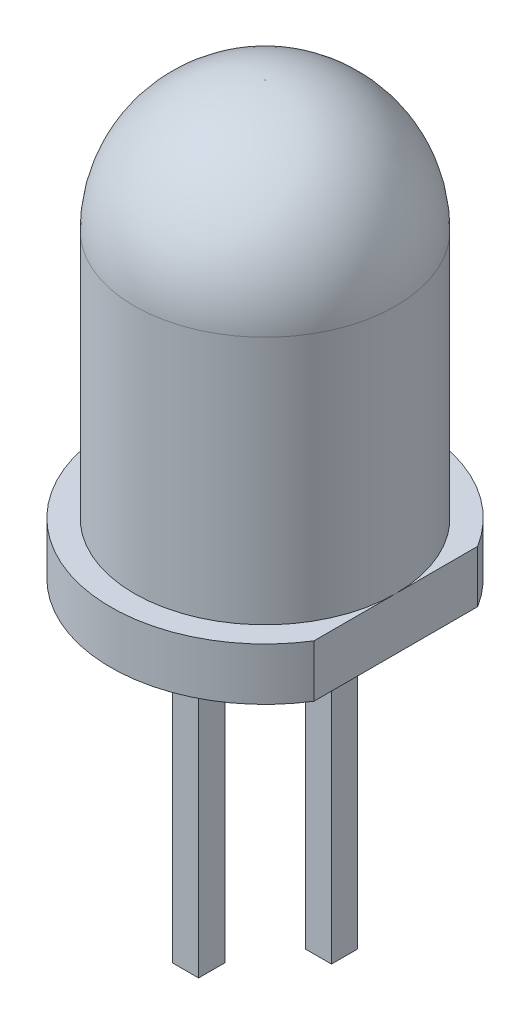
from build123d import *

# Parameters (mm, degrees)
CROQUIS1_R           = 2.95
BASE_DEPTH           = 1
CROQUIS2_R           = 2.5
CUERPO_DEL_LED_DEPTH = 7.25
CROQUIS3_W           = 0.5
CROQUIS3_H           = 0.5
PINES_DEPTH          = 7
CROQUIS4_W           = 0.5
CROQUIS4_H           = 0.5
CORTE_A_CATODO_DEPTH = 1.5
REDONDEO_A_ANODO_R   = 0.5
REDONDEO_A_CATODO_R  = 0.5
CROQUIS6_W           = 1
CROQUIS6_H           = 6
RANURA_DEPTH         = 1
PUNTA_DEL_LED_R      = 2.49


with BuildPart() as part:
    # Croquis1 → Base (new body)
    with BuildSketch(Plane(origin=(0, 0, 0), x_dir=(1, 0, 0), z_dir=(0, 1, 0))):
        Circle(CROQUIS1_R)
    extrude(amount=BASE_DEPTH)

    # Croquis2 → Cuerpo del LED (add)
    with BuildSketch(Plane(origin=(0, 1, 0), x_dir=(1, 0, 0), z_dir=(0, 1, 0))):
        Circle(CROQUIS2_R)
    extrude(amount=CUERPO_DEL_LED_DEPTH)

    # Croquis3 → Pines (add)
    with BuildSketch(Plane.XZ):
        with Locations((-1.270142923, 0)):
            Rectangle(CROQUIS3_W, CROQUIS3_H)
        with Locations((1.270172723, 0)):
            Rectangle(CROQUIS3_W, CROQUIS3_H)
    extrude(amount=PINES_DEPTH)

    # Croquis4 → Corte a Catodo (cut)
    with BuildSketch(Plane.XZ.offset(7)):
        with Locations((1.270172723, 0)):
            Rectangle(CROQUIS4_W, CROQUIS4_H)
    extrude(amount=-CORTE_A_CATODO_DEPTH, mode=Mode.SUBTRACT)

    # Redondeo a Anodo
    redondeo_a_anodo_edges = [part.edges().sort_by_distance(p)[0] for p in [
        (-1.520142923, 0, 0),
        (-1.270142923, 0, -0.25),
        (-1.020142923, 0, 0),
        (-1.270142923, 0, 0.25),
    ]]
    fillet(redondeo_a_anodo_edges, radius=REDONDEO_A_ANODO_R)

    # Redondeo a Catodo
    redondeo_a_catodo_edges = [part.edges().sort_by_distance(p)[0] for p in [
        (1.020172723, 0, 0),
        (1.270172723, 0, -0.25),
        (1.520172723, 0, 0),
        (1.270172723, 0, 0.25),
    ]]
    fillet(redondeo_a_catodo_edges, radius=REDONDEO_A_CATODO_R)

    # Croquis6 → Ranura (cut)
    with BuildSketch(Plane(origin=(0, 1, 0), x_dir=(1, 0, 0), z_dir=(0, 1, 0))):
        with Locations((3, -0.26955261)):
            Rectangle(CROQUIS6_W, CROQUIS6_H)
    extrude(amount=-RANURA_DEPTH, mode=Mode.SUBTRACT)

    # Punta del Led
    punta_del_led_edges = [part.edges().sort_by_distance(p)[0] for p in [
        (-2.5, 8.25, 0),
    ]]
    fillet(punta_del_led_edges, radius=PUNTA_DEL_LED_R)


solid = part.part
